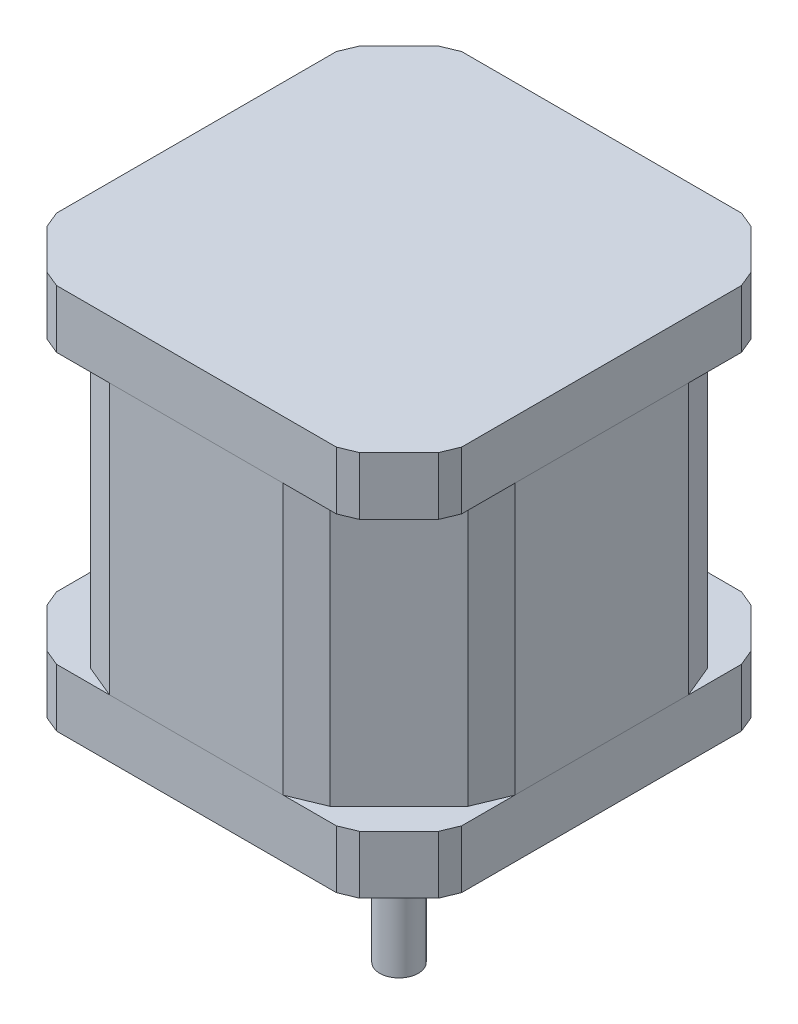
from build123d import *

# Parameters (mm, degrees)
SKETCH_1_W          = 42
SKETCH_1_H          = 42
EXTRUDE_1_DEPTH     = 6
CHAMFER_1_SIZE      = 5.5
SKETCH_2_W          = 42
SKETCH_2_H          = 42
EXTRUDE_3_DEPTH     = 28
CHAMFER_3_SIZE      = 10
CHAMFER_4_SIZE      = 2
SKETCH_4_W          = 42
SKETCH_4_H          = 42
EXTRUDE_6_DEPTH     = 6
CHAMFER_5_SIZE      = 5.5
CHAMFER_6_SIZE      = 1
CHAMFER_7_SIZE      = 1
SKETCH_5_R          = 1.5
CUT_EXTRUDE_1_DEPTH = 5
SKETCH_6_R          = 11
EXTRUDE_7_DEPTH     = 1.5
SKETCH_7_R          = 2
EXTRUDE_8_DEPTH     = 22.5


with BuildPart() as part:
    # 草图1 → 凸台-拉伸1 (new body)
    with BuildSketch(Plane(origin=(0, 0, 0), x_dir=(1, 0, 0), z_dir=(0, 1, 0))):
        with Locations((21, 21)):
            Rectangle(SKETCH_1_W, SKETCH_1_H)
    extrude(amount=EXTRUDE_1_DEPTH)

    # 倒角1
    chamfer_1_edges = [part.edges().sort_by_distance(p)[0] for p in [
        (0, 3, -42),
        (42, 3, -42),
        (42, 3, 0),
        (0, 3, 0),
    ]]
    chamfer(chamfer_1_edges, length=CHAMFER_1_SIZE)

    # 倒角7
    chamfer_7_edges = [part.edges().sort_by_distance(p)[0] for p in [
        (0, 3, -5.5),
        (0, 3, -36.5),
        (36.5, 3, -42),
        (5.5, 3, -42),
        (42, 3, -5.5),
        (42, 3, -36.5),
        (5.5, 3, 0),
        (36.5, 3, 0),
    ]]
    chamfer(chamfer_7_edges, length=CHAMFER_7_SIZE)


with BuildPart() as body_2:
    # 草图2 → 凸台-拉伸3 (new body)
    with BuildSketch(Plane(origin=(0, 0, 0), x_dir=(1, 0, 0), z_dir=(0, 1, 0))):
        with Locations((21, 21)):
            Rectangle(SKETCH_2_W, SKETCH_2_H)
    extrude(amount=-EXTRUDE_3_DEPTH)

    # 倒角3
    chamfer_3_edges = [body_2.edges().sort_by_distance(p)[0] for p in [
        (0, -14, 0),
        (0, -14, -42),
        (42, -14, -42),
        (42, -14, 0),
    ]]
    chamfer(chamfer_3_edges, length=CHAMFER_3_SIZE)

    # 倒角4
    chamfer_4_edges = [body_2.edges().sort_by_distance(p)[0] for p in [
        (42, -14, -10),
        (42, -14, -32),
        (10, -14, -42),
        (32, -14, -42),
        (10, -14, 0),
        (32, -14, 0),
        (0, -14, -32),
        (0, -14, -10),
    ]]
    chamfer(chamfer_4_edges, length=CHAMFER_4_SIZE)


with BuildPart() as body_3:
    # 草图4 → 凸台-拉伸6 (new body)
    with BuildSketch(Plane(origin=(0, -28, 0), x_dir=(-1, 0, 0), z_dir=(0, -1, 0))):
        with Locations((-21, 21)):
            Rectangle(SKETCH_4_W, SKETCH_4_H)
    extrude(amount=EXTRUDE_6_DEPTH)

    # 倒角5
    chamfer_5_edges = [body_3.edges().sort_by_distance(p)[0] for p in [
        (0, -31, 0),
        (42, -31, 0),
        (42, -31, -42),
        (0, -31, -42),
    ]]
    chamfer(chamfer_5_edges, length=CHAMFER_5_SIZE)

    # 倒角6
    chamfer_6_edges = [body_3.edges().sort_by_distance(p)[0] for p in [
        (0, -31, -36.5),
        (0, -31, -5.5),
        (36.5, -31, 0),
        (5.5, -31, 0),
        (42, -31, -36.5),
        (42, -31, -5.5),
        (36.5, -31, -42),
        (5.5, -31, -42),
    ]]
    chamfer(chamfer_6_edges, length=CHAMFER_6_SIZE)

    # 草图5 → 切除-拉伸1 (cut)
    with BuildSketch(Plane(origin=(0, -34, 0), x_dir=(-1, 0, 0), z_dir=(0, -1, 0))):
        with Locations((-5.5, 5.5)):
            Circle(SKETCH_5_R)
        with Locations((-36.5, 5.5)):
            Circle(SKETCH_5_R)
        with Locations((-36.5, 36.5)):
            Circle(SKETCH_5_R)
        with Locations((-5.5, 36.5)):
            Circle(SKETCH_5_R)
    extrude(amount=-CUT_EXTRUDE_1_DEPTH, mode=Mode.SUBTRACT)

    # 草图6 → 凸台-拉伸7 (add)
    with BuildSketch(Plane(origin=(0, -34, 0), x_dir=(-1, 0, 0), z_dir=(0, -1, 0))):
        with Locations((-21, 21)):
            Circle(SKETCH_6_R)
    extrude(amount=EXTRUDE_7_DEPTH)

    # 草图7 → 凸台-拉伸8 (add)
    with BuildSketch(Plane(origin=(0, -35.5, 0), x_dir=(-1, 0, 0), z_dir=(0, -1, 0))):
        with Locations((-21, 21)):
            Circle(SKETCH_7_R)
    extrude(amount=EXTRUDE_8_DEPTH)


solid = Compound([part.part, body_2.part, body_3.part])
